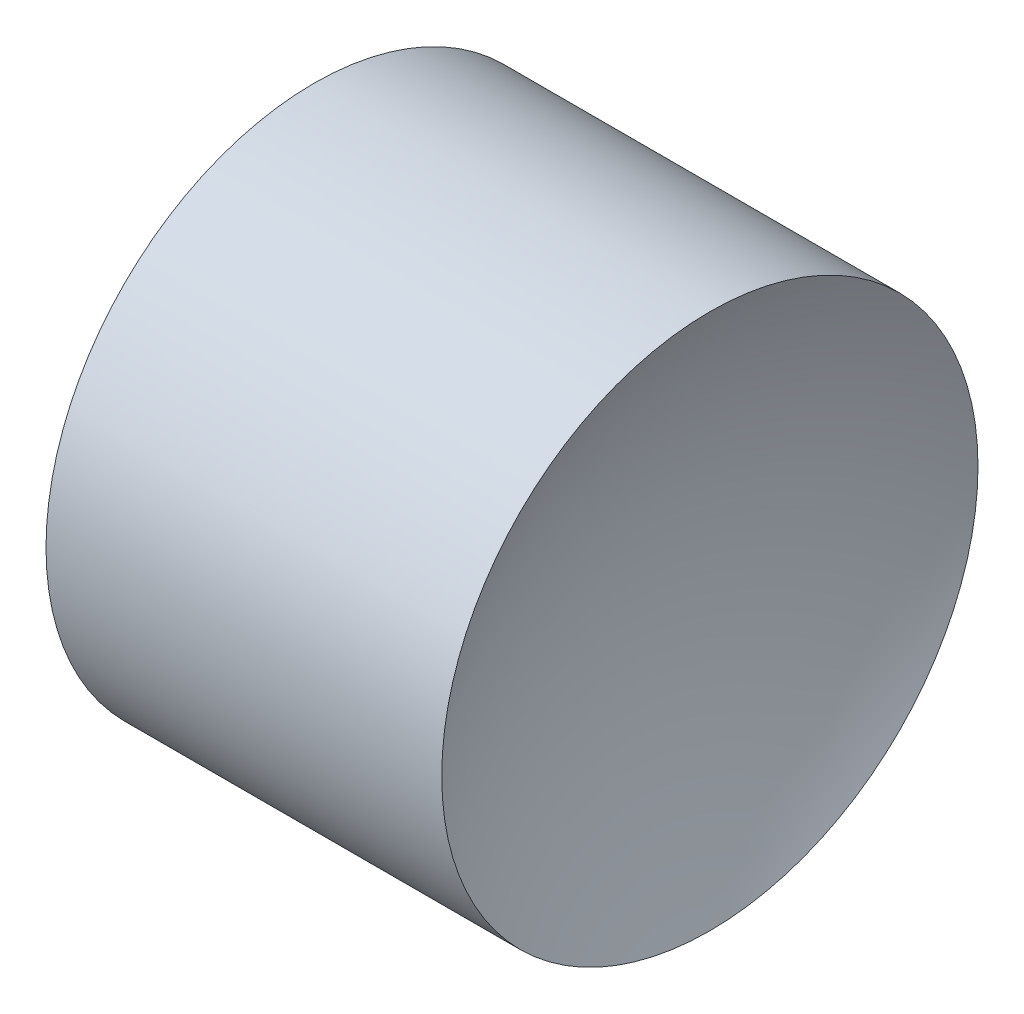
from build123d import *


with BuildPart() as part:
    # 草图1 → 旋转1 (revolve)
    with BuildSketch(Plane.XY, mode=Mode.PRIVATE) as revolve_1_sk:
        with BuildLine():
            Line((6.489613269, 3.261130144), (5.489613269, 3.261130144))
            ThreePointArc((5.489613269, 3.261130144), (5.429298728, 3.775093876), (5.251632441, 4.261130144))
            Line((5.251632441, 4.261130144), (5.989613269, 4.261130144))
            Line((5.989613269, 4.261130144), (6.727594096, 4.261130144))
            ThreePointArc((6.727594096, 4.261130144), (6.54992781, 3.775093876), (6.489613269, 3.261130144))
        make_face()
    revolve(revolve_1_sk.sketch.rotate(Axis((5.306232639, 3.261130144, 0), (1, 0, 0)), 90), axis=Axis((5.306232639, 3.261130144, 0), (1, 0, 0)))  # turned: the seam where the file's is


solid = part.part
